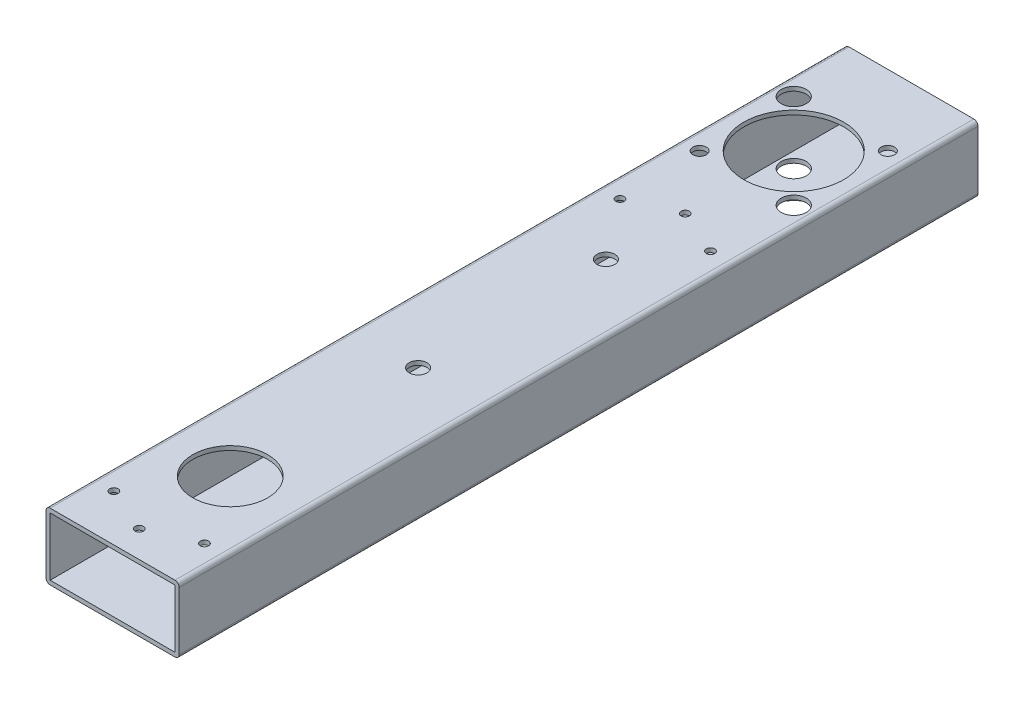
from build123d import *

# Parameters (mm, degrees)
SKETCH1_W                      = 47.625
SKETCH1_H                      = 22.225
BOSS_EXTRUDE1_DEPTH            = 304.8
CUT_EXTRUDE1_REACH             = 27.4
SKETCH2_R                      = 14.2875
SKETCH2_R_2                    = 19.05
CUT_EXTRUDE1_DIRECTION_2_DEPTH = 1
CUT_EXTRUDE2_REACH             = 27.4
SKETCH3_R                      = 12.7
CUT_EXTRUDE2_DIRECTION_2_DEPTH = 1
SKETCH7_R                      = 4.7625
CUT_EXTRUDE3_DEPTH             = 24.8125
CUT_EXTRUDE3_DEPTH_BACK        = 2.5875
CUT_EXTRUDE4_REACH             = 27.4
SKETCH8_R                      = 3.3782
CUT_EXTRUDE4_DIRECTION_2_DEPTH = 1
CUT_EXTRUDE5_REACH             = 27.4
SKETCH9_R                      = 7.9375
CUT_EXTRUDE5_DIRECTION_2_DEPTH = 1
CUT_EXTRUDE6_REACH             = 27.4
SKETCH10_R                     = 1.5875
CUT_EXTRUDE6_DIRECTION_2_DEPTH = 1


with BuildPart() as part:
    # Sketch1 → Boss-Extrude1 (new body)
    with BuildSketch(Plane.XY):
        with BuildLine():
            Line((-23.8125, -12.7), (23.8125, -12.7))
            ThreePointArc((23.8125, -12.7), (24.935032015, -12.235032015), (25.4, -11.1125))
            Line((25.4, -11.1125), (25.4, 11.1125))
            ThreePointArc((25.4, 11.1125), (24.935032015, 12.235032015), (23.8125, 12.7))
            Line((23.8125, 12.7), (-23.8125, 12.7))
            ThreePointArc((-23.8125, 12.7), (-24.935032015, 12.235032015), (-25.4, 11.1125))
            Line((-25.4, 11.1125), (-25.4, -11.1125))
            ThreePointArc((-25.4, -11.1125), (-24.935032015, -12.235032015), (-23.8125, -12.7))
        make_face()
        Rectangle(SKETCH1_W, SKETCH1_H, mode=Mode.SUBTRACT)
    extrude(amount=BOSS_EXTRUDE1_DEPTH)

    # Sketch2 → Cut-Extrude1 (cut, up to next)
    with BuildSketch(Plane(origin=(0, 12.7, 0), x_dir=(1, 0, 0), z_dir=(0, 1, 0)), mode=Mode.PRIVATE) as cut_extrude1_sk1:
        with Locations((0, -259.9)):
            Circle(SKETCH2_R)
    cut_extrude1_tool1 = extrude(cut_extrude1_sk1.sketch, amount=-CUT_EXTRUDE1_REACH, mode=Mode.PRIVATE) & part.part
    add(cut_extrude1_tool1.solids().sort_by_distance((0, 12.7, 259.9))[0], mode=Mode.SUBTRACT)
    # Sketch2 → Cut-Extrude1 (cut, up to next)
    with BuildSketch(Plane(origin=(0, 12.7, 0), x_dir=(1, 0, 0), z_dir=(0, 1, 0)), mode=Mode.PRIVATE) as cut_extrude1_sk2:
        with Locations((0, -44.9)):
            Circle(SKETCH2_R_2)
    cut_extrude1_tool2 = extrude(cut_extrude1_sk2.sketch, amount=-CUT_EXTRUDE1_REACH, mode=Mode.PRIVATE) & part.part
    add(cut_extrude1_tool2.solids().sort_by_distance((0, 12.7, 44.9))[0], mode=Mode.SUBTRACT)

    # Sketch2 → Cut-Extrude1 direction 2 (cut)
    with BuildSketch(Plane(origin=(0, 12.7, 0), x_dir=(1, 0, 0), z_dir=(0, 1, 0))):
        with Locations((0, -259.9)):
            Circle(SKETCH2_R)
        with Locations((0, -44.9)):
            Circle(SKETCH2_R_2)
    extrude(amount=CUT_EXTRUDE1_DIRECTION_2_DEPTH, mode=Mode.SUBTRACT)

    # Sketch3 → Cut-Extrude2 (cut, up to next)
    with BuildSketch(Plane.XZ.offset(12.7), mode=Mode.PRIVATE) as cut_extrude2_sk1:
        with Locations((0, 44.9)):
            Circle(SKETCH3_R)
    cut_extrude2_tool1 = extrude(cut_extrude2_sk1.sketch, amount=-CUT_EXTRUDE2_REACH, mode=Mode.PRIVATE) & part.part
    add(cut_extrude2_tool1.solids().sort_by_distance((0, -12.7, 44.9))[0], mode=Mode.SUBTRACT)
    # Sketch3 → Cut-Extrude2 (cut, up to next)
    with BuildSketch(Plane.XZ.offset(12.7), mode=Mode.PRIVATE) as cut_extrude2_sk2:
        with Locations((0, 259.9)):
            Circle(SKETCH3_R)
    cut_extrude2_tool2 = extrude(cut_extrude2_sk2.sketch, amount=-CUT_EXTRUDE2_REACH, mode=Mode.PRIVATE) & part.part
    add(cut_extrude2_tool2.solids().sort_by_distance((0, -12.7, 259.9))[0], mode=Mode.SUBTRACT)

    # Sketch3 → Cut-Extrude2 direction 2 (cut)
    with BuildSketch(Plane.XZ.offset(12.7)):
        with Locations((0, 44.9)):
            Circle(SKETCH3_R)
        with Locations((0, 259.9)):
            Circle(SKETCH3_R)
    extrude(amount=CUT_EXTRUDE2_DIRECTION_2_DEPTH, mode=Mode.SUBTRACT)

    # Sketch7 → Cut-Extrude3 (cut, two sides)
    with BuildSketch(Plane.XZ.offset(-11.1125)) as cut_extrude3_sk:
        with Locations((17.960512242, 62.860512242)):
            Circle(SKETCH7_R)
        with Locations((-17.960512242, 26.939487758)):
            Circle(SKETCH7_R)
        with BuildLine():
            ThreePointArc((20.513212242, 26.939487758), (17.960512242, 29.492187758), (15.407812242, 26.939487758))
            ThreePointArc((15.407812242, 26.939487758), (17.960512242, 24.386787758), (20.513212242, 26.939487758))
        make_face()
        with BuildLine():
            ThreePointArc((-15.407812242, 62.860512242), (-17.960512242, 65.413212242), (-20.513212242, 62.860512242))
            ThreePointArc((-20.513212242, 62.860512242), (-17.960512242, 60.307812242), (-15.407812242, 62.860512242))
        make_face()
    extrude(amount=CUT_EXTRUDE3_DEPTH, mode=Mode.SUBTRACT)
    extrude(cut_extrude3_sk.sketch, amount=-CUT_EXTRUDE3_DEPTH_BACK, mode=Mode.SUBTRACT)

    # Sketch8 → Cut-Extrude4 (cut, up to next)
    with BuildSketch(Plane(origin=(0, 12.7, 0), x_dir=(1, 0, 0), z_dir=(0, 1, 0)), mode=Mode.PRIVATE) as cut_extrude4_sk1:
        with Locations((0, -116.566667182)):
            Circle(SKETCH8_R)
    cut_extrude4_tool1 = extrude(cut_extrude4_sk1.sketch, amount=-CUT_EXTRUDE4_REACH, mode=Mode.PRIVATE) & part.part
    add(cut_extrude4_tool1.solids().sort_by_distance((0, 12.7, 116.566667))[0], mode=Mode.SUBTRACT)
    # Sketch8 → Cut-Extrude4 (cut, up to next)
    with BuildSketch(Plane(origin=(0, 12.7, 0), x_dir=(1, 0, 0), z_dir=(0, 1, 0)), mode=Mode.PRIVATE) as cut_extrude4_sk2:
        with Locations((0, -188.233332818)):
            Circle(SKETCH8_R)
    cut_extrude4_tool2 = extrude(cut_extrude4_sk2.sketch, amount=-CUT_EXTRUDE4_REACH, mode=Mode.PRIVATE) & part.part
    add(cut_extrude4_tool2.solids().sort_by_distance((0, 12.7, 188.233333))[0], mode=Mode.SUBTRACT)

    # Sketch8 → Cut-Extrude4 direction 2 (cut)
    with BuildSketch(Plane(origin=(0, 12.7, 0), x_dir=(1, 0, 0), z_dir=(0, 1, 0))):
        with Locations((0, -116.566667182)):
            Circle(SKETCH8_R)
        with Locations((0, -188.233332818)):
            Circle(SKETCH8_R)
    extrude(amount=CUT_EXTRUDE4_DIRECTION_2_DEPTH, mode=Mode.SUBTRACT)

    # Sketch9 → Cut-Extrude5 (cut, up to next)
    with BuildSketch(Plane.XZ.offset(12.7), mode=Mode.PRIVATE) as cut_extrude5_sk1:
        with Locations((0, 116.566667182)):
            Circle(SKETCH9_R)
    cut_extrude5_tool1 = extrude(cut_extrude5_sk1.sketch, amount=-CUT_EXTRUDE5_REACH, mode=Mode.PRIVATE) & part.part
    add(cut_extrude5_tool1.solids().sort_by_distance((0, -12.7, 116.566667))[0], mode=Mode.SUBTRACT)
    # Sketch9 → Cut-Extrude5 (cut, up to next)
    with BuildSketch(Plane.XZ.offset(12.7), mode=Mode.PRIVATE) as cut_extrude5_sk2:
        with Locations((0, 188.233332818)):
            Circle(SKETCH9_R)
    cut_extrude5_tool2 = extrude(cut_extrude5_sk2.sketch, amount=-CUT_EXTRUDE5_REACH, mode=Mode.PRIVATE) & part.part
    add(cut_extrude5_tool2.solids().sort_by_distance((0, -12.7, 188.233333))[0], mode=Mode.SUBTRACT)

    # Sketch9 → Cut-Extrude5 direction 2 (cut)
    with BuildSketch(Plane.XZ.offset(12.7)):
        with Locations((0, 116.566667182)):
            Circle(SKETCH9_R)
        with Locations((0, 188.233332818)):
            Circle(SKETCH9_R)
    extrude(amount=CUT_EXTRUDE5_DIRECTION_2_DEPTH, mode=Mode.SUBTRACT)

    # Sketch10 → Cut-Extrude6 (cut, up to next)
    with BuildSketch(Plane(origin=(0, 12.7, 0), x_dir=(1, 0, 0), z_dir=(0, 1, 0)), mode=Mode.PRIVATE) as cut_extrude6_sk1:
        with Locations((17.272, -287.02)):
            Circle(SKETCH10_R)
    cut_extrude6_tool1 = extrude(cut_extrude6_sk1.sketch, amount=-CUT_EXTRUDE6_REACH, mode=Mode.PRIVATE) & part.part
    add(cut_extrude6_tool1.solids().sort_by_distance((17.272, 12.7, 287.02))[0], mode=Mode.SUBTRACT)
    # Sketch10 → Cut-Extrude6 (cut, up to next)
    with BuildSketch(Plane(origin=(0, 12.7, 0), x_dir=(1, 0, 0), z_dir=(0, 1, 0)), mode=Mode.PRIVATE) as cut_extrude6_sk2:
        with Locations((-17.272, -287.02)):
            Circle(SKETCH10_R)
    cut_extrude6_tool2 = extrude(cut_extrude6_sk2.sketch, amount=-CUT_EXTRUDE6_REACH, mode=Mode.PRIVATE) & part.part
    add(cut_extrude6_tool2.solids().sort_by_distance((-17.272, 12.7, 287.02))[0], mode=Mode.SUBTRACT)
    # Sketch10 → Cut-Extrude6 (cut, up to next)
    with BuildSketch(Plane(origin=(0, 12.7, 0), x_dir=(1, 0, 0), z_dir=(0, 1, 0)), mode=Mode.PRIVATE) as cut_extrude6_sk3:
        with Locations((0, -294.64)):
            Circle(SKETCH10_R)
    cut_extrude6_tool3 = extrude(cut_extrude6_sk3.sketch, amount=-CUT_EXTRUDE6_REACH, mode=Mode.PRIVATE) & part.part
    add(cut_extrude6_tool3.solids().sort_by_distance((0, 12.7, 294.64))[0], mode=Mode.SUBTRACT)
    # Sketch10 → Cut-Extrude6 (cut, up to next)
    with BuildSketch(Plane(origin=(0, 12.7, 0), x_dir=(1, 0, 0), z_dir=(0, 1, 0)), mode=Mode.PRIVATE) as cut_extrude6_sk4:
        with Locations((17.272, -93.922)):
            Circle(SKETCH10_R)
    cut_extrude6_tool4 = extrude(cut_extrude6_sk4.sketch, amount=-CUT_EXTRUDE6_REACH, mode=Mode.PRIVATE) & part.part
    add(cut_extrude6_tool4.solids().sort_by_distance((17.272, 12.7, 93.922))[0], mode=Mode.SUBTRACT)
    # Sketch10 → Cut-Extrude6 (cut, up to next)
    with BuildSketch(Plane(origin=(0, 12.7, 0), x_dir=(1, 0, 0), z_dir=(0, 1, 0)), mode=Mode.PRIVATE) as cut_extrude6_sk5:
        with Locations((0, -86.302)):
            Circle(SKETCH10_R)
    cut_extrude6_tool5 = extrude(cut_extrude6_sk5.sketch, amount=-CUT_EXTRUDE6_REACH, mode=Mode.PRIVATE) & part.part
    add(cut_extrude6_tool5.solids().sort_by_distance((0, 12.7, 86.302))[0], mode=Mode.SUBTRACT)
    # Sketch10 → Cut-Extrude6 (cut, up to next)
    with BuildSketch(Plane(origin=(0, 12.7, 0), x_dir=(1, 0, 0), z_dir=(0, 1, 0)), mode=Mode.PRIVATE) as cut_extrude6_sk6:
        with Locations((-17.272, -93.922)):
            Circle(SKETCH10_R)
    cut_extrude6_tool6 = extrude(cut_extrude6_sk6.sketch, amount=-CUT_EXTRUDE6_REACH, mode=Mode.PRIVATE) & part.part
    add(cut_extrude6_tool6.solids().sort_by_distance((-17.272, 12.7, 93.922))[0], mode=Mode.SUBTRACT)

    # Sketch10 → Cut-Extrude6 direction 2 (cut)
    with BuildSketch(Plane(origin=(0, 12.7, 0), x_dir=(1, 0, 0), z_dir=(0, 1, 0))):
        with Locations((17.272, -287.02)):
            Circle(SKETCH10_R)
        with Locations((-17.272, -287.02)):
            Circle(SKETCH10_R)
        with Locations((0, -294.64)):
            Circle(SKETCH10_R)
        with Locations((17.272, -93.922)):
            Circle(SKETCH10_R)
        with Locations((0, -86.302)):
            Circle(SKETCH10_R)
        with Locations((-17.272, -93.922)):
            Circle(SKETCH10_R)
    extrude(amount=CUT_EXTRUDE6_DIRECTION_2_DEPTH, mode=Mode.SUBTRACT)


solid = part.part
